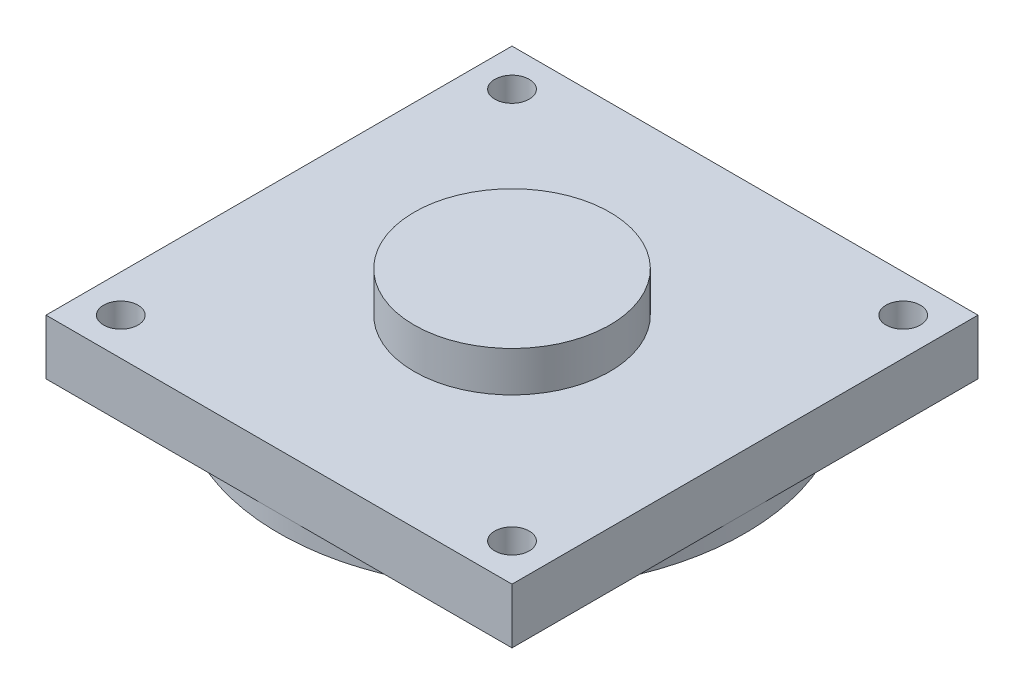
from build123d import *

# Parameters (mm, degrees)
SKETCH1_W           = 40.5
SKETCH1_H           = 40.5
BOSS_EXTRUDE1_DEPTH = 4.8
SKETCH2_R           = 8.5
BOSS_EXTRUDE2_DEPTH = 3.5
SKETCH3_R           = 1.5
CUT_EXTRUDE1_DEPTH  = 4.8
SKETCH4_R           = 20.25
BOSS_EXTRUDE3_DEPTH = 1.5


with BuildPart() as part:
    # Sketch1 → Boss-Extrude1 (new body)
    with BuildSketch(Plane(origin=(0, 0, 0), x_dir=(1, 0, 0), z_dir=(0, 1, 0))):
        Rectangle(SKETCH1_W, SKETCH1_H)
    extrude(amount=BOSS_EXTRUDE1_DEPTH)

    # Sketch2 → Boss-Extrude2 (add)
    with BuildSketch(Plane(origin=(0, 4.8, 0), x_dir=(1, 0, 0), z_dir=(0, 1, 0))):
        Circle(SKETCH2_R)
    extrude(amount=BOSS_EXTRUDE2_DEPTH)

    # Sketch3 → Cut-Extrude1 (cut)
    with BuildSketch(Plane(origin=(0, 4.8, 0), x_dir=(1, 0, 0), z_dir=(0, 1, 0))):
        with Locations((17, 17)):
            Circle(SKETCH3_R)
        with Locations((-17, 17)):
            Circle(SKETCH3_R)
        with Locations((-17, -17)):
            Circle(SKETCH3_R)
        with Locations((17, -17)):
            Circle(SKETCH3_R)
    extrude(amount=-CUT_EXTRUDE1_DEPTH, mode=Mode.SUBTRACT)

    # Sketch4 → Boss-Extrude3 (add)
    with BuildSketch(Plane(origin=(0, 0, 0), x_dir=(-1, 0, 0), z_dir=(0, -1, 0))):
        Circle(SKETCH4_R)
    extrude(amount=BOSS_EXTRUDE3_DEPTH)


solid = part.part
